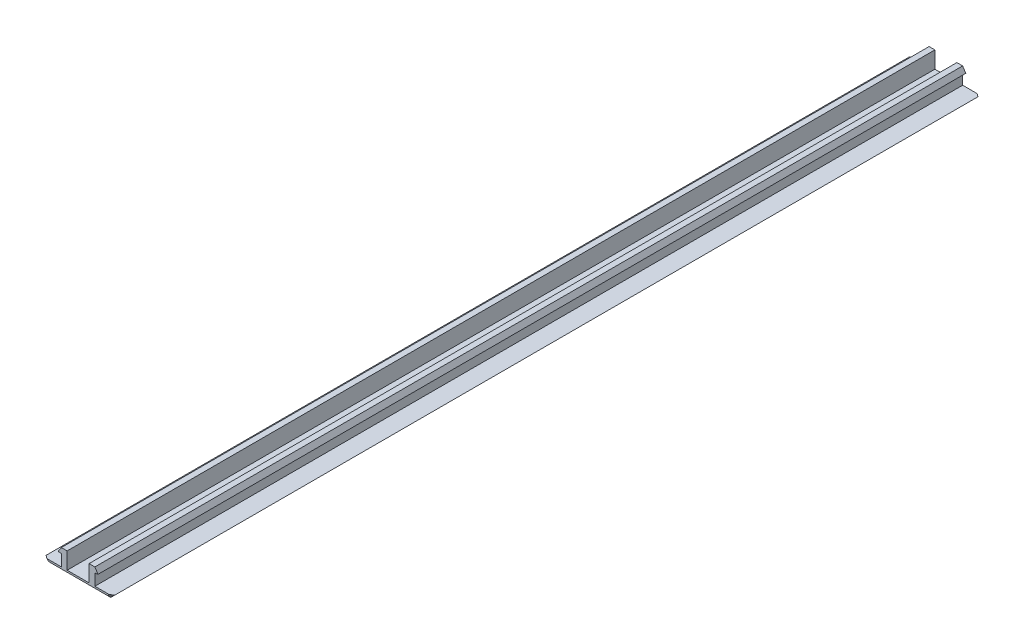
from build123d import *

# Parameters (mm, degrees)
BOSS_EXTRUDE1_DEPTH = 150
CHAMFER2_SIZE       = 0.4


with BuildPart() as part:
    # Sketch1 → Boss-Extrude1 (new body)
    with BuildSketch(Plane.XY):
        Polygon((5.95, 0.70711), (2.9, 0.70711), (2.9, 2.68877), (3.438098658, 2.759612032), (2.9, 3.60069), (1.9, 3.60069), (1.9, 0.70711), (-1.9, 0.70711), (-1.9, 3.60069), (-2.9, 3.60069), (-3.438098658, 2.759612032), (-2.9, 2.68877), (-2.9, 0.70711), (-5.95, 0.70711), (-5.24289, 0), (5.24289, 0), align=None)
    extrude(amount=BOSS_EXTRUDE1_DEPTH)

    # Chamfer2
    chamfer2_edges = [part.edges().sort_by_distance(p)[0] for p in [
        (5.596445, 0.353555, 0),
        (0, 0, 0),
        (-5.596445, 0.353555, 0),
        (-5.596445, 0.353555, 150),
        (0, 0, 150),
        (5.596445, 0.353555, 150),
    ]]
    chamfer(chamfer2_edges, length=CHAMFER2_SIZE)


solid = part.part
